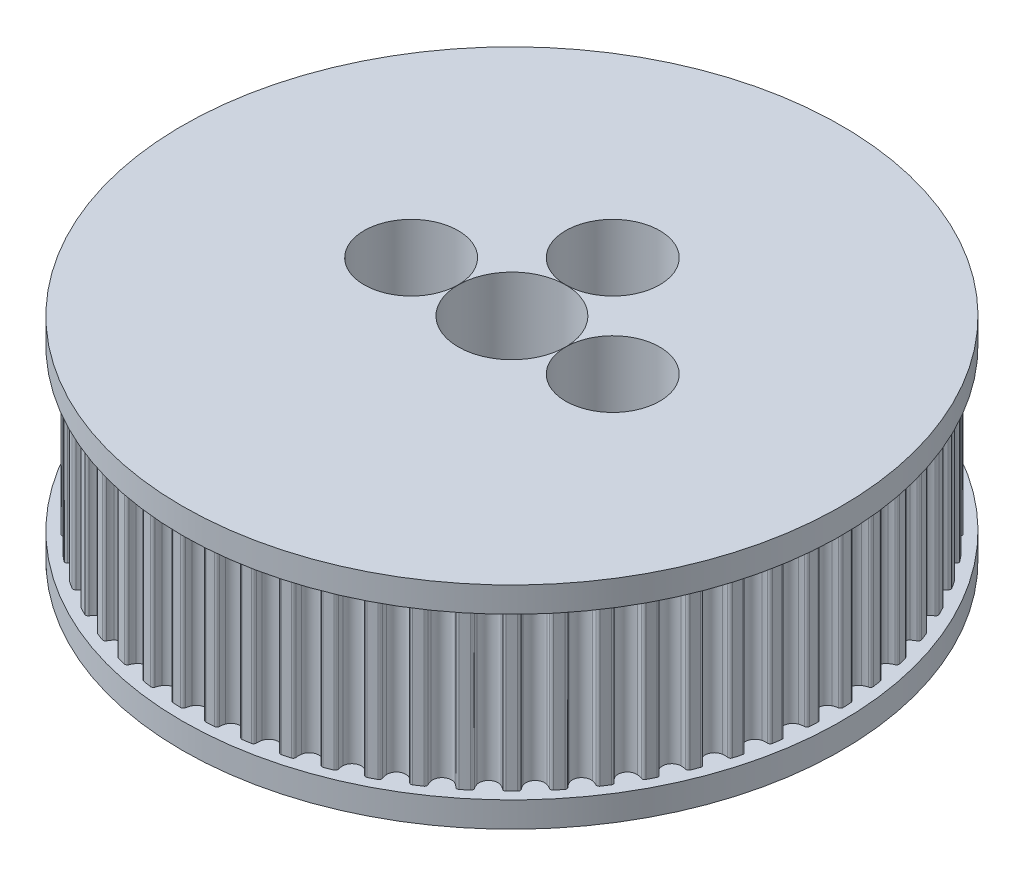
from build123d import *

# Parameters (mm, degrees)
GT2_SKETCH_R                                        = 18.844593171
GT2_SKETCH_R_2                                      = 3.175
PULLEY_BODY_DEPTH                                   = 9.5
TOOTH_EXTRUDE_DEPTH                                 = 29.292885741
TOOTH_PATTERN_COUNT                                 = 60
GT2_SKETCH_4_R                                      = 19.474593171
GT2_SKETCH_4_R_2                                    = 3.175
BOTTOM_RETAINER_BOSS_EXTRUDE2_DEPTH                 = 1.5
TOP_START                                           = 9.5
GT2_SKETCH_5_R                                      = 19.474593171
GT2_SKETCH_5_R_2                                    = 18.844593171
GT2_SKETCH_5_R_3                                    = 3.175
TOP_RETAINER_BOSS_EXTRUDE3_DEPTH                    = 1.5
CBORE_FOR_2_BINDING_HEAD_MACHINE_SCREW1_D           = 2.2606
CBORE_FOR_2_BINDING_HEAD_MACHINE_SCREW1_CBORE_D     = 5.55752
CBORE_FOR_2_BINDING_HEAD_MACHINE_SCREW1_CBORE_DEPTH = 8


with BuildPart() as part:
    # GT2 Sketch → Pulley Body (new body)
    with BuildSketch(Plane(origin=(0, 0, 0), x_dir=(1, 0, 0), z_dir=(0, 1, 0))):
        with Locations(Location((0, 0, 0), (0, 0, 270))):
            Circle(GT2_SKETCH_R)
        with Locations(Location((0, 0, 0), (0, 0, 270))):
            Circle(GT2_SKETCH_R_2, mode=Mode.SUBTRACT)
    extrude(amount=PULLEY_BODY_DEPTH)

    # GT2 Sketch_3 → Tooth Extrude (cut, through all)
    with BuildSketch(Plane(origin=(0, 0, 0), x_dir=(1, 0, 0), z_dir=(0, 1, 0))):
        with BuildLine():
            ThreePointArc((0.59023039, 18.700906509), (0.642628143, 18.795132518), (0.744692585, 18.8298732))
            ThreePointArc((0.744692585, 18.8298732), (0, 18.844593171), (-0.744692585, 18.8298732))
            ThreePointArc((-0.744692585, 18.8298732), (-0.642628143, 18.795132518), (-0.59023039, 18.700906509))
            ThreePointArc((-0.59023039, 18.700906509), (-0.556292686, 18.547936262), (-0.498876404, 18.402145196))
            ThreePointArc((-0.498876404, 18.402145196), (0, 18.090347443), (0.498876404, 18.402145196))
            ThreePointArc((0.498876404, 18.402145196), (0.556292686, 18.547936262), (0.59023039, 18.700906509))
        make_face()
    tooth_extrude = extrude(amount=TOOTH_EXTRUDE_DEPTH, mode=Mode.SUBTRACT)

    # Tooth Pattern: Tooth Extrude ×60 about axis
    tooth_pattern_axis = Axis((0, 0, 0), (0, 1, 0))
    for i in range(1, TOOTH_PATTERN_COUNT):
        add(tooth_extrude.rotate(tooth_pattern_axis, i * 360 / TOOTH_PATTERN_COUNT), mode=Mode.SUBTRACT)

    # GT2 Sketch_4 → Bottom Retainer Boss-Extrude2 (add)
    with BuildSketch(Plane(origin=(0, 0, 0), x_dir=(1, 0, 0), z_dir=(0, 1, 0))):
        with Locations(Location((0, 0, 0), (0, 0, 270))):
            Circle(GT2_SKETCH_4_R)
        with Locations(Location((0, 0, 0), (0, 0, 270))):
            Circle(GT2_SKETCH_4_R_2, mode=Mode.SUBTRACT)
    extrude(amount=-BOTTOM_RETAINER_BOSS_EXTRUDE2_DEPTH)

    # GT2 Sketch_5 → Top Retainer Boss-Extrude3 (add)
    with BuildSketch(Plane(origin=(0, 0, 0), x_dir=(1, 0, 0), z_dir=(0, 1, 0)).offset(TOP_START)):
        with Locations(Location((0, 0, 0), (0, 0, 270))):
            Circle(GT2_SKETCH_5_R)
        Circle(GT2_SKETCH_5_R_2, mode=Mode.SUBTRACT)
        with BuildLine():
            ThreePointArc((-0.744692585, 18.8298732), (-13.059197199, -13.585877237), (18.844593171, 0))
            ThreePointArc((18.844593171, 0), (13.585877237, 13.059197199), (0.744692585, 18.8298732))
            ThreePointArc((0.744692585, 18.8298732), (0.642628143, 18.795132518), (0.59023039, 18.700906509))
            ThreePointArc((0.59023039, 18.700906509), (0.556292686, 18.547936262), (0.498876404, 18.402145196))
            ThreePointArc((0.498876404, 18.402145196), (0, 18.090347443), (-0.498876404, 18.402145196))
            ThreePointArc((-0.498876404, 18.402145196), (-0.556292686, 18.547936262), (-0.59023039, 18.700906509))
            ThreePointArc((-0.59023039, 18.700906509), (-0.642628143, 18.795132518), (-0.744692585, 18.8298732))
        make_face()
        with Locations(Location((0, 0, 0), (0, 0, 270))):
            Circle(GT2_SKETCH_5_R_3, mode=Mode.SUBTRACT)
        with BuildLine():
            ThreePointArc((0.59023039, 18.700906509), (0.642628143, 18.795132518), (0.744692585, 18.8298732))
            ThreePointArc((0.744692585, 18.8298732), (0, 18.844593171), (-0.744692585, 18.8298732))
            ThreePointArc((-0.744692585, 18.8298732), (-0.642628143, 18.795132518), (-0.59023039, 18.700906509))
            ThreePointArc((-0.59023039, 18.700906509), (-0.556292686, 18.547936262), (-0.498876404, 18.402145196))
            ThreePointArc((-0.498876404, 18.402145196), (0, 18.090347443), (0.498876404, 18.402145196))
            ThreePointArc((0.498876404, 18.402145196), (0.556292686, 18.547936262), (0.59023039, 18.700906509))
        make_face()
    extrude(amount=TOP_RETAINER_BOSS_EXTRUDE3_DEPTH)

    # CBORE for _2 Binding Head Machine Screw1 (through all)
    with Locations(Plane(origin=(0, 11, 0), x_dir=(1, 0, 0), z_dir=(0, 1, 0))):
        with Locations((-5.9563, 0), (0, 5.9563), (5.9563, 0)):
            CounterBoreHole(CBORE_FOR_2_BINDING_HEAD_MACHINE_SCREW1_D / 2, CBORE_FOR_2_BINDING_HEAD_MACHINE_SCREW1_CBORE_D / 2, CBORE_FOR_2_BINDING_HEAD_MACHINE_SCREW1_CBORE_DEPTH)


solid = part.part
